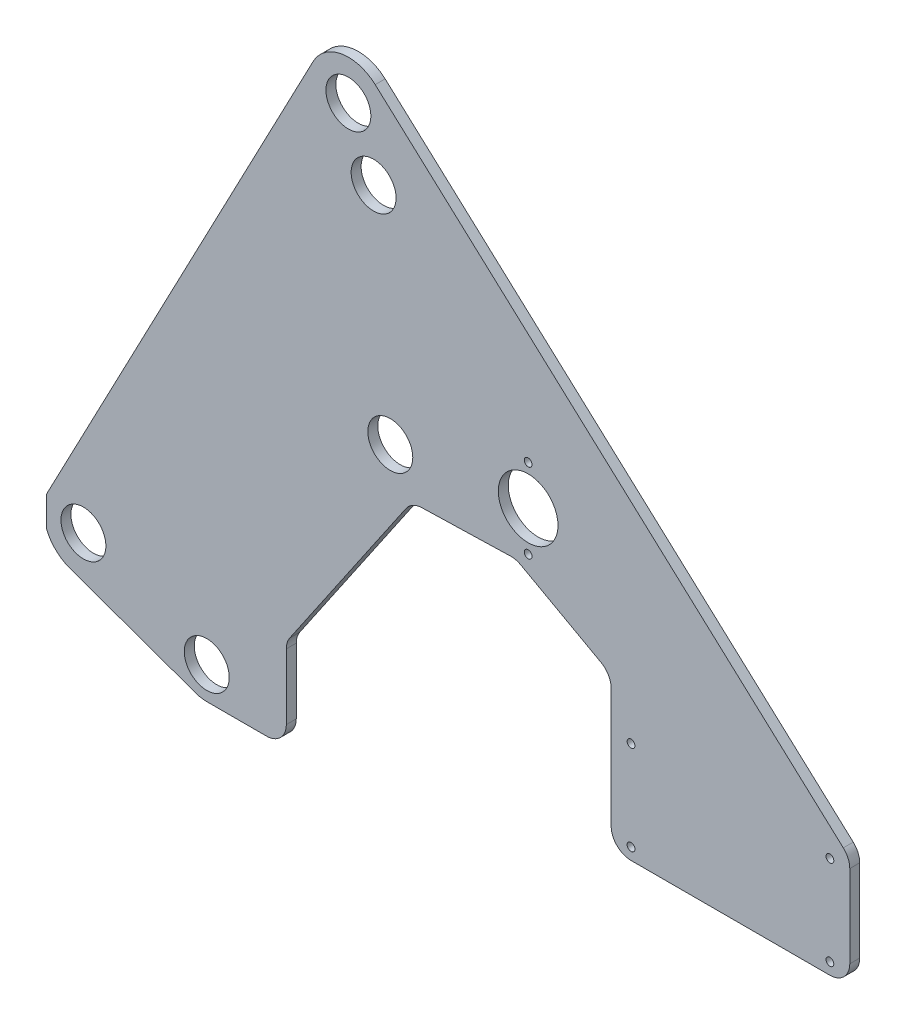
from build123d import *

# Parameters (mm, degrees)
MODEL_R             = 2.4892
MODEL_R_2           = 14.351
MODEL_R_3           = 19.05
BOSS_EXTRUDE1_DEPTH = 6.35


with BuildPart() as part:
    # Model → Boss-Extrude1 (new body)
    with BuildSketch(Plane.XY):
        with BuildLine():
            Line((-441.789312, -6.889165677), (-441.789312, -25.038634323))
            ThreePointArc((-441.789312, -25.038634323), (-435.829532347, -34.118973304), (-426.62152736, -39.879543908))
            Line((-426.62152736, -39.879543908), (-346.203265936, -68.649155922))
            ThreePointArc((-346.203265936, -68.649155922), (-342.794136372, -69.547563331), (-339.28161131, -69.85))
            Line((-339.28161131, -69.85), (-301.18161131, -69.85))
            ThreePointArc((-301.18161131, -69.85), (-292.201355189, -66.130256121), (-288.48161131, -57.15))
            Line((-288.48161131, -57.15), (-288.48161131, -15.263054603))
            ThreePointArc((-288.48161131, -15.263054603), (-287.916123528, -11.515573687), (-286.270018677, -8.101817916))
            Line((-286.270018677, -8.101817916), (-212.077490922, 100.561181044))
            ThreePointArc((-212.077490922, 100.561181044), (-207.671459082, 104.548698007), (-201.933730241, 106.095267065))
            Line((-201.933730241, 106.095267065), (-145.278114328, 107.633327242))
            ThreePointArc((-145.278114328, 107.633327242), (-141.931465661, 107.278101134), (-138.795626118, 106.056318319))
            Line((-138.795626118, 106.056318319), (-87.594102076, 77.790625657))
            ThreePointArc((-87.594102076, 77.790625657), (-82.794837325, 73.127519562), (-81.0319436, 66.672311872))
            Line((-81.0319436, 66.672311872), (-81.0319436, -9.525))
            ThreePointArc((-81.0319436, -9.525), (-77.312199721, -18.505256121), (-68.3319436, -22.225))
            Line((-68.3319436, -22.225), (58.6680564, -22.225))
            ThreePointArc((58.6680564, -22.225), (67.648312521, -18.505256121), (71.3680564, -9.525))
            Line((71.3680564, -9.525), (71.3680564, 43.162005366))
            ThreePointArc((71.3680564, 43.162005366), (70.286480643, 48.290574182), (67.225974809, 52.545609817))
            Line((67.225974809, 52.545609817), (-231.724912696, 325.191085975))
            ThreePointArc((-231.724912696, 325.191085975), (-253.238197861, 331.440320626), (-271.33067791, 318.229092902))
            Line((-271.33067791, 318.229092902), (-440.555640395, -4.158684171))
            ThreePointArc((-440.555640395, -4.158684171), (-441.212773023, -5.505718227), (-441.789312, -6.889165677))
        make_face()
        with Locations((58.6680564, 42.418)):
            Circle(MODEL_R, mode=Mode.SUBTRACT)
        with Locations((-248.840749515, 306.423877073)):
            Circle(MODEL_R_2, mode=Mode.SUBTRACT)
        with Locations((-232.729624751, 269.086142594)):
            Circle(MODEL_R_2, mode=Mode.SUBTRACT)
        with Locations((-134.044120223, 165.1)):
            Circle(MODEL_R, mode=Mode.SUBTRACT)
        with Locations((-68.3319436, 42.418)):
            Circle(MODEL_R, mode=Mode.SUBTRACT)
        with Locations((-134.044120223, 114.3)):
            Circle(MODEL_R, mode=Mode.SUBTRACT)
        with Locations((58.6680564, -14.732)):
            Circle(MODEL_R, mode=Mode.SUBTRACT)
        with Locations((-339.28161131, -49.3014)):
            Circle(MODEL_R_2, mode=Mode.SUBTRACT)
        with Locations((-418.065712, -15.9639)):
            Circle(MODEL_R_2, mode=Mode.SUBTRACT)
        with Locations((-222.079312, 130.957722259)):
            Circle(MODEL_R_2, mode=Mode.SUBTRACT)
        with Locations((-134.044120223, 139.7)):
            Circle(MODEL_R_3, mode=Mode.SUBTRACT)
        with Locations((-68.3319436, -14.732)):
            Circle(MODEL_R, mode=Mode.SUBTRACT)
    extrude(amount=BOSS_EXTRUDE1_DEPTH)


solid = part.part
